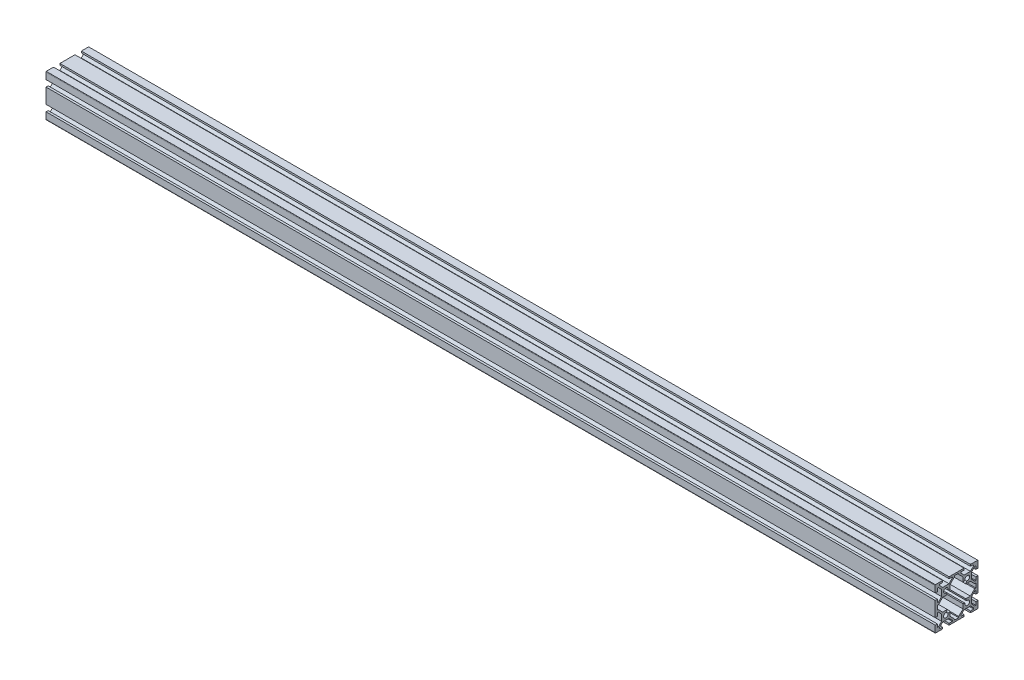
from build123d import *

# Parameters (mm, degrees)
BOSS_EXTRUDE1_DEPTH = 830


with BuildPart() as part:
    # Sketch1 → Boss-Extrude1 (new body)
    with BuildSketch(Plane(origin=(0, 0, 0), x_dir=(0, 0, -1), z_dir=(1, 0, 0))):
        with BuildLine():
            Line((-20, 19), (-20, 13))
            Line((-20, 13), (-18, 13))
            Line((-18, 13), (-18, 16))
            Line((-18, 16), (-17.060660172, 16))
            Line((-17.060660172, 16), (-14, 12.939339828))
            Line((-14, 12.939339828), (-14, 7.060660172))
            Line((-14, 7.060660172), (-17.060660172, 4))
            Line((-17.060660172, 4), (-18, 4))
            Line((-18, 4), (-18, 7))
            Line((-18, 7), (-20, 7))
            Line((-20, 7), (-20, -7))
            Line((-20, -7), (-18, -7))
            Line((-18, -7), (-18, -4))
            Line((-18, -4), (-17.060660172, -4))
            Line((-17.060660172, -4), (-14, -7.060660172))
            Line((-14, -7.060660172), (-14, -12.939339828))
            Line((-14, -12.939339828), (-17.060660172, -16))
            Line((-17.060660172, -16), (-18, -16))
            Line((-18, -16), (-18, -13))
            Line((-18, -13), (-20, -13))
            Line((-20, -13), (-20, -19))
            ThreePointArc((-20, -19), (-19.948683298, -19.316227766), (-19.8, -19.6))
            Line((-19.8, -19.6), (-13, -19.6))
            Line((-13, -19.6), (-13, -18))
            Line((-13, -18), (-16, -18))
            Line((-16, -18), (-16, -17.060660172))
            Line((-16, -17.060660172), (-12.939339828, -14))
            Line((-12.939339828, -14), (-7.060660172, -14))
            Line((-7.060660172, -14), (-4, -17.060660172))
            Line((-4, -17.060660172), (-4, -18))
            Line((-4, -18), (-7, -18))
            Line((-7, -18), (-7, -19.6))
            Line((-7, -19.6), (7, -19.6))
            Line((7, -19.6), (7, -18))
            Line((7, -18), (4, -18))
            Line((4, -18), (4, -17.060660172))
            Line((4, -17.060660172), (7.060660172, -14))
            Line((7.060660172, -14), (12.939339828, -14))
            Line((12.939339828, -14), (16, -17.060660172))
            Line((16, -17.060660172), (16, -18))
            Line((16, -18), (13, -18))
            Line((13, -18), (13, -19.6))
            Line((13, -19.6), (19.8, -19.6))
            ThreePointArc((19.8, -19.6), (19.948683298, -19.316227766), (20, -19))
            Line((20, -19), (20, -13))
            Line((20, -13), (18, -13))
            Line((18, -13), (18, -16))
            Line((18, -16), (17.060660172, -16))
            Line((17.060660172, -16), (14, -12.939339828))
            Line((14, -12.939339828), (14, -7.060660172))
            Line((14, -7.060660172), (17.060660172, -4))
            Line((17.060660172, -4), (18, -4))
            Line((18, -4), (18, -7))
            Line((18, -7), (20, -7))
            Line((20, -7), (20, 7))
            Line((20, 7), (18, 7))
            Line((18, 7), (18, 4))
            Line((18, 4), (17.060660172, 4))
            Line((17.060660172, 4), (14, 7.060660172))
            Line((14, 7.060660172), (14, 12.939339828))
            Line((14, 12.939339828), (17.060660172, 16))
            Line((17.060660172, 16), (18, 16))
            Line((18, 16), (18, 13))
            Line((18, 13), (20, 13))
            Line((20, 13), (20, 19))
            ThreePointArc((20, 19), (19.948683298, 19.316227766), (19.8, 19.6))
            Line((19.8, 19.6), (13, 19.6))
            Line((13, 19.6), (13, 18))
            Line((13, 18), (16, 18))
            Line((16, 18), (16, 17.060660172))
            Line((16, 17.060660172), (12.939339828, 14))
            Line((12.939339828, 14), (7.060660172, 14))
            Line((7.060660172, 14), (4, 17.060660172))
            Line((4, 17.060660172), (4, 18))
            Line((4, 18), (7, 18))
            Line((7, 18), (7, 19.6))
            Line((7, 19.6), (-7, 19.6))
            Line((-7, 19.6), (-7, 18))
            Line((-7, 18), (-4, 18))
            Line((-4, 18), (-4, 17.060660172))
            Line((-4, 17.060660172), (-7.060660172, 14))
            Line((-7.060660172, 14), (-12.939339828, 14))
            Line((-12.939339828, 14), (-16, 17.060660172))
            Line((-16, 17.060660172), (-16, 18))
            Line((-16, 18), (-13, 18))
            Line((-13, 18), (-13, 19.6))
            Line((-13, 19.6), (-19.8, 19.6))
            ThreePointArc((-19.8, 19.6), (-19.948683298, 19.316227766), (-20, 19))
        make_face()
        with BuildLine():
            Line((-16.939339828, 2), (-18, 2))
            Line((-18, 2), (-18, -2))
            Line((-18, -2), (-16.939339828, -2))
            Line((-16.939339828, -2), (-12.939339828, -6))
            Line((-12.939339828, -6), (-8.666662697, -6))
            Line((-8.666662697, -6), (-9.335919912, -8.007765667))
            ThreePointArc((-9.335919912, -8.007765667), (-11.48492424, -11.48492424), (-8.007765667, -9.335919912))
            Line((-8.007765667, -9.335919912), (-6, -8.666662697))
            Line((-6, -8.666662697), (-6, -12.939339828))
            Line((-6, -12.939339828), (-2, -16.939339828))
            Line((-2, -16.939339828), (-2, -18))
            Line((-2, -18), (2, -18))
            Line((2, -18), (2, -16.939339828))
            Line((2, -16.939339828), (6, -12.939339828))
            Line((6, -12.939339828), (6, -8.666662697))
            Line((6, -8.666662697), (8.007765667, -9.335919912))
            ThreePointArc((8.007765667, -9.335919912), (11.48492424, -11.48492424), (9.335919912, -8.007765667))
            Line((9.335919912, -8.007765667), (8.666662697, -6))
            Line((8.666662697, -6), (12.939339828, -6))
            Line((12.939339828, -6), (16.939339828, -2))
            Line((16.939339828, -2), (18, -2))
            Line((18, -2), (18, 2))
            Line((18, 2), (16.939339828, 2))
            Line((16.939339828, 2), (12.939339828, 6))
            Line((12.939339828, 6), (8.666662697, 6))
            Line((8.666662697, 6), (9.335919912, 8.007765667))
            ThreePointArc((9.335919912, 8.007765667), (11.48492424, 11.48492424), (8.007765667, 9.335919912))
            Line((8.007765667, 9.335919912), (6, 8.666662697))
            Line((6, 8.666662697), (6, 12.939339828))
            Line((6, 12.939339828), (2, 16.939339828))
            Line((2, 16.939339828), (2, 18))
            Line((2, 18), (-2, 18))
            Line((-2, 18), (-2, 16.939339828))
            Line((-2, 16.939339828), (-6, 12.939339828))
            Line((-6, 12.939339828), (-6, 8.666662697))
            Line((-6, 8.666662697), (-8.007765667, 9.335919912))
            ThreePointArc((-8.007765667, 9.335919912), (-11.48492424, 11.48492424), (-9.335919912, 8.007765667))
            Line((-9.335919912, 8.007765667), (-8.666662697, 6))
            Line((-8.666662697, 6), (-12.939339828, 6))
            Line((-12.939339828, 6), (-16.939339828, 2))
        make_face(mode=Mode.SUBTRACT)
    extrude(amount=BOSS_EXTRUDE1_DEPTH)


solid = part.part
